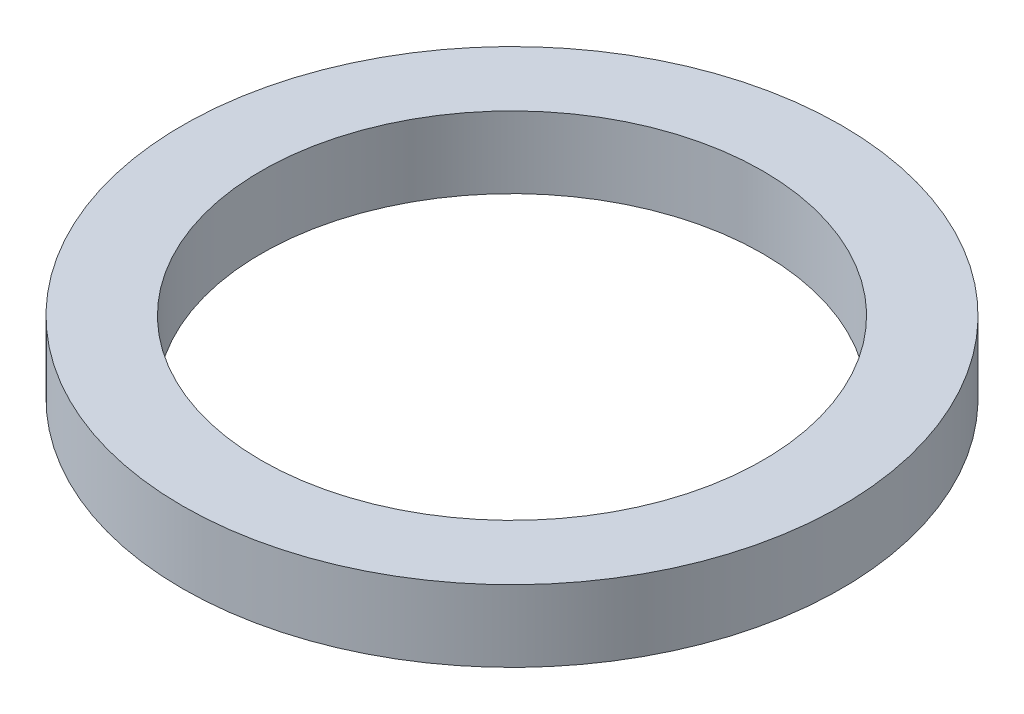
from build123d import *

# Parameters (mm, degrees)
SKETCH1_R           = 2.3
BOSS_EXTRUDE1_DEPTH = 0.5
SKETCH2_R           = 1.75
CUT_EXTRUDE1_DEPTH  = 1.5


with BuildPart() as part:
    # Sketch1 → Boss-Extrude1 (new body)
    with BuildSketch(Plane(origin=(0, 0, 0), x_dir=(1, 0, 0), z_dir=(0, 1, 0))):
        Circle(SKETCH1_R)
    extrude(amount=BOSS_EXTRUDE1_DEPTH)

    # Sketch2 → Cut-Extrude1 (cut, through all)
    with BuildSketch(Plane(origin=(0, 0.5, 0), x_dir=(1, 0, 0), z_dir=(0, 1, 0))):
        Circle(SKETCH2_R)
    extrude(amount=-CUT_EXTRUDE1_DEPTH, mode=Mode.SUBTRACT)


solid = part.part
